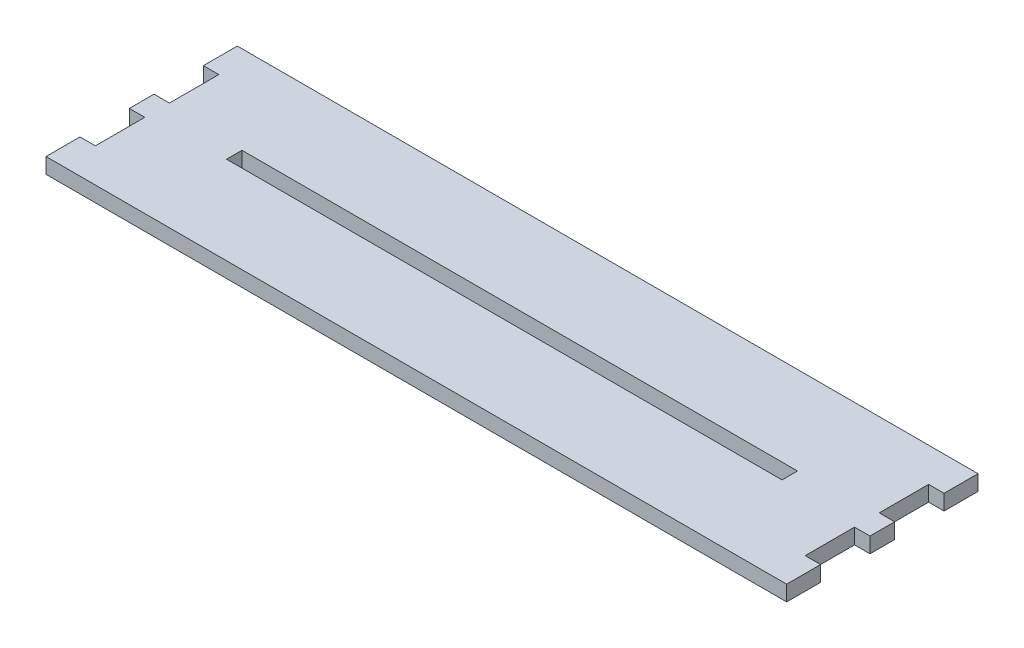
from build123d import *

# Parameters (mm, degrees)
BOSS_EXTRUDE1_DEPTH = 3.175
SKETCH2_W           = 114.3
SKETCH2_H           = 3.175
CUT_EXTRUDE1_DEPTH  = 4.175


with BuildPart() as part:
    # Sketch1 → Boss-Extrude1 (new body)
    with BuildSketch(Plane(origin=(0, 0, 0), x_dir=(1, 0, 0), z_dir=(0, 1, 0))):
        Polygon((-42.852622222, 17.463911111), (109.547377778, 17.463911111), (109.547377778, 10.478911111), (106.372377778, 10.478911111), (106.372377778, 0.318911111), (109.547377778, 0.318911111), (109.547377778, -4.761088889), (106.372377778, -4.761088889), (106.372377778, -14.921088889), (109.547377778, -14.921088889), (109.547377778, -21.906088889), (-42.852622222, -21.906088889), (-42.852622222, -14.921088889), (-39.677622222, -14.921088889), (-39.677622222, -4.761088889), (-42.852622222, -4.761088889), (-42.852622222, 0.318911111), (-39.677622222, 0.318911111), (-39.677622222, 10.478911111), (-42.852622222, 10.478911111), align=None)
    extrude(amount=BOSS_EXTRUDE1_DEPTH)

    # Sketch2 → Cut-Extrude1 (cut, through all)
    with BuildSketch(Plane(origin=(0, 3.175, 0), x_dir=(1, 0, 0), z_dir=(0, 1, 0))):
        with Locations((33.347377778, -2.221088889)):
            Rectangle(SKETCH2_W, SKETCH2_H)
    extrude(amount=-CUT_EXTRUDE1_DEPTH, mode=Mode.SUBTRACT)


solid = part.part
